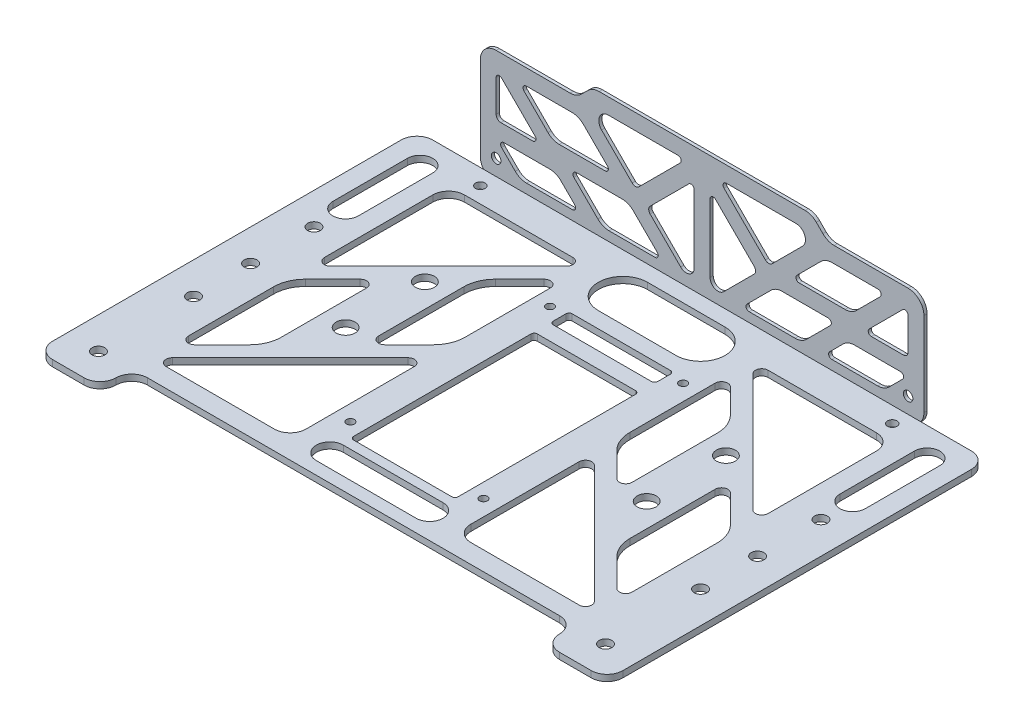
from build123d import *

# Parameters (mm, degrees)
SKETCH_1_R          = 1.25
SKETCH_1_R_2        = 2
SKETCH_1_R_3        = 1.5
SKETCH_1_R_4        = 3
EXTRUDE_1_DEPTH     = 2
SKETCH_3_W          = 33
SKETCH_3_H          = 6
SKETCH_3_H_2        = 58
CUT_EXTRUDE_2_DEPTH = 3
SKETCH_4_R          = 1.5
EXTRUDE_2_DEPTH     = 1
CUT_EXTRUDE_3_DEPTH = 122
CUT_EXTRUDE_4_DEPTH = 3
FILLET_1_R          = 1


with BuildPart() as part:
    # 草图1 → 凸台-拉伸1 (new body)
    with BuildSketch(Plane(origin=(0, 0, 0), x_dir=(1, 0, 0), z_dir=(0, 1, 0))):
        with BuildLine():
            Line((-85, 58.5), (85, 58.5))
            ThreePointArc((85, 58.5), (88.535533906, 57.035533906), (90, 53.5))
            Line((90, 53.5), (90, -56.5))
            ThreePointArc((90, -56.5), (88.535533906, -60.035533906), (85, -61.5))
            Line((85, -61.5), (75, -61.5))
            ThreePointArc((75, -61.5), (71.464466094, -60.035533906), (70, -56.5))
            ThreePointArc((70, -56.5), (68.535533906, -52.964466094), (65, -51.5))
            Line((65, -51.5), (-65, -51.5))
            ThreePointArc((-65, -51.5), (-68.535533906, -52.964466094), (-70, -56.5))
            ThreePointArc((-70, -56.5), (-71.464466094, -60.035533906), (-75, -61.5))
            Line((-75, -61.5), (-85, -61.5))
            ThreePointArc((-85, -61.5), (-88.535533906, -60.035533906), (-90, -56.5))
            Line((-90, -56.5), (-90, 53.5))
            ThreePointArc((-90, 53.5), (-88.535533906, 57.035533906), (-85, 58.5))
        make_face()
        with Locations((-21, 31.5)):
            Circle(SKETCH_1_R, mode=Mode.SUBTRACT)
        with Locations((-21, -31.5)):
            Circle(SKETCH_1_R, mode=Mode.SUBTRACT)
        with Locations((21, -31.5)):
            Circle(SKETCH_1_R, mode=Mode.SUBTRACT)
        with Locations((21, 31.5)):
            Circle(SKETCH_1_R, mode=Mode.SUBTRACT)
        with Locations((-80, -52)):
            Circle(SKETCH_1_R_2, mode=Mode.SUBTRACT)
        with Locations((80, -52)):
            Circle(SKETCH_1_R_2, mode=Mode.SUBTRACT)
        with Locations((-80, 16)):
            Circle(SKETCH_1_R_2, mode=Mode.SUBTRACT)
        with Locations((-80, -4)):
            Circle(SKETCH_1_R_2, mode=Mode.SUBTRACT)
        with Locations((-80, -22)):
            Circle(SKETCH_1_R_2, mode=Mode.SUBTRACT)
        with Locations((80, -22)):
            Circle(SKETCH_1_R_2, mode=Mode.SUBTRACT)
        with Locations((80, -4)):
            Circle(SKETCH_1_R_2, mode=Mode.SUBTRACT)
        with Locations((80, 16)):
            Circle(SKETCH_1_R_2, mode=Mode.SUBTRACT)
        with Locations((-65, 53.5)):
            Circle(SKETCH_1_R_3, mode=Mode.SUBTRACT)
        with Locations((65, 53.5)):
            Circle(SKETCH_1_R_3, mode=Mode.SUBTRACT)
        with Locations((-47.5, -6.5)):
            Circle(SKETCH_1_R_4, mode=Mode.SUBTRACT)
        with Locations((-47.5, 18.5)):
            Circle(SKETCH_1_R_4, mode=Mode.SUBTRACT)
        with Locations((47.5, 18.5)):
            Circle(SKETCH_1_R_4, mode=Mode.SUBTRACT)
        with Locations((47.5, -6.5)):
            Circle(SKETCH_1_R_4, mode=Mode.SUBTRACT)
    extrude(amount=EXTRUDE_1_DEPTH)

    # 草图3 → 切除-拉伸2 (cut, through all)
    with BuildSketch(Plane(origin=(0, 2, 0), x_dir=(1, 0, 0), z_dir=(0, 1, 0))):
        with Locations((0, 30)):
            Rectangle(SKETCH_3_W, SKETCH_3_H)
        with Locations((0, -7)):
            Rectangle(SKETCH_3_W, SKETCH_3_H_2)
    extrude(amount=-CUT_EXTRUDE_2_DEPTH, mode=Mode.SUBTRACT)

    # 草图6 → 切除-拉伸4 (cut, through all)
    with BuildSketch(Plane(origin=(0, 2, 0), x_dir=(1, 0, 0), z_dir=(0, 1, 0))):
        with BuildLine():
            Line((-65, 48.5), (-30.828427125, 48.5))
            ThreePointArc((-30.828427125, 48.5), (-28.98066806, 47.265366865), (-29.414213562, 45.085786438))
            Line((-29.414213562, 45.085786438), (-66.585786438, 7.914213562))
            ThreePointArc((-66.585786438, 7.914213562), (-68.765366865, 7.48066806), (-70, 9.328427125))
            Line((-70, 9.328427125), (-70, 43.5))
            ThreePointArc((-70, 43.5), (-68.535533906, 47.035533906), (-65, 48.5))
        make_face()
        with BuildLine():
            Line((-26, -6.328427125), (-26, -40.5))
            ThreePointArc((-26, -40.5), (-27.464466094, -44.035533906), (-31, -45.5))
            Line((-31, -45.5), (-65.171572875, -45.5))
            ThreePointArc((-65.171572875, -45.5), (-67.01933194, -44.265366865), (-66.585786438, -42.085786438))
            Line((-66.585786438, -42.085786438), (-29.414213562, -4.914213562))
            ThreePointArc((-29.414213562, -4.914213562), (-27.234633135, -4.48066806), (-26, -6.328427125))
        make_face()
        with BuildLine():
            Line((-55, 7.600505063), (-55, -19.286796564))
            ThreePointArc((-55, -19.286796564), (-55.761204675, -23.113630888), (-57.928932188, -26.357864376))
            Line((-57.928932188, -26.357864376), (-66.585786438, -35.014718626))
            ThreePointArc((-66.585786438, -35.014718626), (-68.765366865, -35.448264128), (-70, -33.600505063))
            Line((-70, -33.600505063), (-70, -6.713203436))
            ThreePointArc((-70, -6.713203436), (-69.238795325, -2.886369112), (-67.071067812, 0.357864376))
            Line((-67.071067812, 0.357864376), (-58.414213562, 9.014718626))
            ThreePointArc((-58.414213562, 9.014718626), (-56.234633135, 9.448264128), (-55, 7.600505063))
        make_face()
        with BuildLine():
            Line((-40, 23.286796564), (-40, -3.600505063))
            ThreePointArc((-40, -3.600505063), (-38.765366865, -5.448264128), (-36.585786438, -5.014718626))
            Line((-36.585786438, -5.014718626), (-28.928932188, 2.642135624))
            ThreePointArc((-28.928932188, 2.642135624), (-26.761204675, 5.886369112), (-26, 9.713203436))
            Line((-26, 9.713203436), (-26, 36.600505063))
            ThreePointArc((-26, 36.600505063), (-27.234633135, 38.448264128), (-29.414213562, 38.014718626))
            Line((-29.414213562, 38.014718626), (-37.071067812, 30.357864376))
            ThreePointArc((-37.071067812, 30.357864376), (-39.238795325, 27.113630888), (-40, 23.286796564))
        make_face()
        with BuildLine():
            Line((-12.25, 53.5), (12.25, 53.5))
            ThreePointArc((12.25, 53.5), (20, 45.75), (12.25, 38))
            Line((12.25, 38), (-12.25, 38))
            ThreePointArc((-12.25, 38), (-20, 45.75), (-12.25, 53.5))
        make_face()
        with BuildLine():
            Line((15.75, -47.5), (-15.75, -47.5))
            ThreePointArc((-15.75, -47.5), (-20, -43.25), (-15.75, -39))
            Line((-15.75, -39), (15.75, -39))
            ThreePointArc((15.75, -39), (20, -43.25), (15.75, -47.5))
        make_face()
        with BuildLine():
            Line((29.414213562, 38.014718626), (37.071067812, 30.357864376))
            ThreePointArc((37.071067812, 30.357864376), (39.238795325, 27.113630888), (40, 23.286796564))
            Line((40, 23.286796564), (40, -3.600505063))
            ThreePointArc((40, -3.600505063), (38.765366865, -5.448264128), (36.585786438, -5.014718626))
            Line((36.585786438, -5.014718626), (28.928932188, 2.642135624))
            ThreePointArc((28.928932188, 2.642135624), (26.761204675, 5.886369112), (26, 9.713203436))
            Line((26, 9.713203436), (26, 36.600505063))
            ThreePointArc((26, 36.600505063), (27.234633135, 38.448264128), (29.414213562, 38.014718626))
        make_face()
        with BuildLine():
            Line((67.071067812, 0.357864376), (58.414213562, 9.014718626))
            ThreePointArc((58.414213562, 9.014718626), (56.234633135, 9.448264128), (55, 7.600505063))
            Line((55, 7.600505063), (55, -19.286796564))
            ThreePointArc((55, -19.286796564), (55.761204675, -23.113630888), (57.928932188, -26.357864376))
            Line((57.928932188, -26.357864376), (66.585786438, -35.014718626))
            ThreePointArc((66.585786438, -35.014718626), (68.765366865, -35.448264128), (70, -33.600505063))
            Line((70, -33.600505063), (70, -6.713203436))
            ThreePointArc((70, -6.713203436), (69.238795325, -2.886369112), (67.071067812, 0.357864376))
        make_face()
        with BuildLine():
            Line((66.585786438, -42.085786438), (29.414213562, -4.914213562))
            ThreePointArc((29.414213562, -4.914213562), (27.234633135, -4.48066806), (26, -6.328427125))
            Line((26, -6.328427125), (26, -40.5))
            ThreePointArc((26, -40.5), (27.464466094, -44.035533906), (31, -45.5))
            Line((31, -45.5), (65.171572875, -45.5))
            ThreePointArc((65.171572875, -45.5), (67.01933194, -44.265366865), (66.585786438, -42.085786438))
        make_face()
        with BuildLine():
            Line((70, 9.328427125), (70, 43.5))
            ThreePointArc((70, 43.5), (68.535533906, 47.035533906), (65, 48.5))
            Line((65, 48.5), (30.828427125, 48.5))
            ThreePointArc((30.828427125, 48.5), (28.98066806, 47.265366865), (29.414213562, 45.085786438))
            Line((29.414213562, 45.085786438), (66.585786438, 7.914213562))
            ThreePointArc((66.585786438, 7.914213562), (68.765366865, 7.48066806), (70, 9.328427125))
        make_face()
        with BuildLine():
            Line((-76, 49.5), (-76, 26))
            ThreePointArc((-76, 26), (-80, 22), (-84, 26))
            Line((-84, 26), (-84, 49.5))
            ThreePointArc((-84, 49.5), (-80, 53.5), (-76, 49.5))
        make_face()
        with BuildLine():
            Line((76, 49.5), (76, 26))
            ThreePointArc((76, 26), (80, 22), (84, 26))
            Line((84, 26), (84, 49.5))
            ThreePointArc((84, 49.5), (80, 53.5), (76, 49.5))
        make_face()
    extrude(amount=-CUT_EXTRUDE_4_DEPTH, mode=Mode.SUBTRACT)

    # 圆角1
    fillet_1_edges = [part.edges().sort_by_distance(p)[0] for p in [
        (16.5, 1, -22),
        (16.5, 1, 36),
        (-16.5, 1, 36),
        (-16.5, 1, -22),
        (16.5, 1, -33),
        (16.5, 1, -27),
        (-16.5, 1, -27),
        (-16.5, 1, -33),
    ]]
    fillet(fillet_1_edges, radius=FILLET_1_R)


with BuildPart() as body_2:
    # 草图4 → 凸台-拉伸2 (new body)
    with BuildSketch(Plane(origin=(0, 0, -58.5), x_dir=(-1, 0, 0), z_dir=(0, 0, -1))):
        with BuildLine():
            Line((-70, 31.5), (-70, 5))
            ThreePointArc((-70, 5), (-68.535533906, 1.464466094), (-65, 0))
            Line((-65, 0), (65, 0))
            ThreePointArc((65, 0), (68.535533906, 1.464466094), (70, 5))
            Line((70, 5), (70, 31.5))
            ThreePointArc((70, 31.5), (68.535533906, 35.035533906), (65, 36.5))
            Line((65, 36.5), (41.642135624, 36.5))
            ThreePointArc((41.642135624, 36.5), (39.728718462, 36.880602337), (38.106601718, 37.964466094))
            Line((38.106601718, 37.964466094), (36.035533906, 40.035533906))
            ThreePointArc((36.035533906, 40.035533906), (34.413417162, 41.119397663), (32.5, 41.5))
            Line((32.5, 41.5), (-32.5, 41.5))
            ThreePointArc((-32.5, 41.5), (-34.413417162, 41.119397663), (-36.035533906, 40.035533906))
            Line((-36.035533906, 40.035533906), (-38.106601718, 37.964466094))
            ThreePointArc((-38.106601718, 37.964466094), (-39.728718462, 36.880602337), (-41.642135624, 36.5))
            Line((-41.642135624, 36.5), (-65, 36.5))
            ThreePointArc((-65, 36.5), (-68.535533906, 35.035533906), (-70, 31.5))
        make_face()
        with Locations((-65, 7)):
            Circle(SKETCH_4_R, mode=Mode.SUBTRACT)
        with Locations((65, 7)):
            Circle(SKETCH_4_R, mode=Mode.SUBTRACT)
    extrude(amount=EXTRUDE_2_DEPTH)

    # 草图5 → 切除-拉伸3 (cut, through all)
    with BuildSketch(Plane(origin=(0, 0, -59.5), x_dir=(-1, 0, 0), z_dir=(0, 0, -1))):
        with BuildLine():
            Line((-29.615223689, 36.5), (-7.596194078, 36.5))
            ThreePointArc((-7.596194078, 36.5), (-6.672314545, 35.882683432), (-6.889087297, 34.792893219))
            Line((-6.889087297, 34.792893219), (-19.959262274, 21.722718241))
            ThreePointArc((-19.959262274, 21.722718241), (-21.019922446, 21.283378413), (-22.080582618, 21.722718241))
            Line((-22.080582618, 21.722718241), (-31.736544033, 31.378679656))
            ThreePointArc((-31.736544033, 31.378679656), (-32.386862287, 34.648050297), (-29.615223689, 36.5))
        make_face()
        with BuildLine():
            Line((-2.5, 29.696699141), (-2.5, 8.17766953))
            ThreePointArc((-2.5, 8.17766953), (-4.043291419, 5.867970698), (-6.767766953, 6.409902577))
            Line((-6.767766953, 6.409902577), (-16.423728368, 16.065863992))
            ThreePointArc((-16.423728368, 16.065863992), (-16.863068196, 17.126524164), (-16.423728368, 18.187184335))
            Line((-16.423728368, 18.187184335), (-4.207106781, 30.403805922))
            ThreePointArc((-4.207106781, 30.403805922), (-3.117316568, 30.620578674), (-2.5, 29.696699141))
        make_face()
        with BuildLine():
            Line((52.707106781, 19.207106781), (63.292893219, 29.792893219))
            ThreePointArc((63.292893219, 29.792893219), (64.382683432, 30.00966597), (65, 29.085786438))
            Line((65, 29.085786438), (65, 19))
            ThreePointArc((65, 19), (64.560660172, 17.939339828), (63.5, 17.5))
            Line((63.5, 17.5), (53.414213562, 17.5))
            ThreePointArc((53.414213562, 17.5), (52.49033403, 18.117316568), (52.707106781, 19.207106781))
        make_face()
        with BuildLine():
            Line((45.107864376, 20.75), (30.593145751, 20.75))
            ThreePointArc((30.593145751, 20.75), (29.669266218, 21.367316568), (29.886038969, 22.457106781))
            Line((29.886038969, 22.457106781), (37.464466094, 30.035533906))
            ThreePointArc((37.464466094, 30.035533906), (39.086582838, 31.119397663), (41, 31.5))
            Line((41, 31.5), (55.514718626, 31.5))
            ThreePointArc((55.514718626, 31.5), (56.438598158, 30.882683432), (56.221825407, 29.792893219))
            Line((56.221825407, 29.792893219), (48.643398282, 22.214466094))
            ThreePointArc((48.643398282, 22.214466094), (47.021281538, 21.130602337), (45.107864376, 20.75))
        make_face()
        with BuildLine():
            Line((-62.585786438, 12.5), (-48.071067812, 12.5))
            ThreePointArc((-48.071067812, 12.5), (-46.15765065, 12.119397663), (-44.535533906, 11.035533906))
            Line((-44.535533906, 11.035533906), (-40.207106781, 6.707106781))
            ThreePointArc((-40.207106781, 6.707106781), (-39.99033403, 5.617316568), (-40.914213562, 5))
            Line((-40.914213562, 5), (-55.428932188, 5))
            ThreePointArc((-55.428932188, 5), (-57.34234935, 5.380602337), (-58.964466094, 6.464466094))
            Line((-58.964466094, 6.464466094), (-63.292893219, 10.792893219))
            ThreePointArc((-63.292893219, 10.792893219), (-63.50966597, 11.882683432), (-62.585786438, 12.5))
        make_face()
        with BuildLine():
            Line((-55.514718626, 31.5), (-41, 31.5))
            ThreePointArc((-41, 31.5), (-39.086582838, 31.119397663), (-37.464466094, 30.035533906))
            Line((-37.464466094, 30.035533906), (-29.886038969, 22.457106781))
            ThreePointArc((-29.886038969, 22.457106781), (-29.669266218, 21.367316568), (-30.593145751, 20.75))
            Line((-30.593145751, 20.75), (-45.107864376, 20.75))
            ThreePointArc((-45.107864376, 20.75), (-47.021281538, 21.130602337), (-48.643398282, 22.214466094))
            Line((-48.643398282, 22.214466094), (-56.221825407, 29.792893219))
            ThreePointArc((-56.221825407, 29.792893219), (-56.438598158, 30.882683432), (-55.514718626, 31.5))
        make_face()
        with BuildLine():
            Line((-65, 29.085786438), (-65, 19))
            ThreePointArc((-65, 19), (-64.560660172, 17.939339828), (-63.5, 17.5))
            Line((-63.5, 17.5), (-53.414213562, 17.5))
            ThreePointArc((-53.414213562, 17.5), (-52.49033403, 18.117316568), (-52.707106781, 19.207106781))
            Line((-52.707106781, 19.207106781), (-63.292893219, 29.792893219))
            ThreePointArc((-63.292893219, 29.792893219), (-64.382683432, 30.00966597), (-65, 29.085786438))
        make_face()
        with BuildLine():
            Line((55.428932188, 5), (40.914213562, 5))
            ThreePointArc((40.914213562, 5), (39.99033403, 5.617316568), (40.207106781, 6.707106781))
            Line((40.207106781, 6.707106781), (44.535533906, 11.035533906))
            ThreePointArc((44.535533906, 11.035533906), (46.15765065, 12.119397663), (48.071067812, 12.5))
            Line((48.071067812, 12.5), (62.585786438, 12.5))
            ThreePointArc((62.585786438, 12.5), (63.50966597, 11.882683432), (63.292893219, 10.792893219))
            Line((63.292893219, 10.792893219), (58.964466094, 6.464466094))
            ThreePointArc((58.964466094, 6.464466094), (57.34234935, 5.380602337), (55.428932188, 5))
        make_face()
        with BuildLine():
            Line((6.767766953, 6.409902577), (16.423728368, 16.065863992))
            ThreePointArc((16.423728368, 16.065863992), (16.863068196, 17.126524164), (16.423728368, 18.187184335))
            Line((16.423728368, 18.187184335), (4.207106781, 30.403805922))
            ThreePointArc((4.207106781, 30.403805922), (3.117316568, 30.620578674), (2.5, 29.696699141))
            Line((2.5, 29.696699141), (2.5, 8.17766953))
            ThreePointArc((2.5, 8.17766953), (4.043291419, 5.867970698), (6.767766953, 6.409902577))
        make_face()
        with BuildLine():
            Line((29.615223689, 36.5), (7.596194078, 36.5))
            ThreePointArc((7.596194078, 36.5), (6.672314545, 35.882683432), (6.889087297, 34.792893219))
            Line((6.889087297, 34.792893219), (19.959262274, 21.722718241))
            ThreePointArc((19.959262274, 21.722718241), (21.019922446, 21.283378413), (22.080582618, 21.722718241))
            Line((22.080582618, 21.722718241), (31.736544033, 31.378679656))
            ThreePointArc((31.736544033, 31.378679656), (32.386862287, 34.648050297), (29.615223689, 36.5))
        make_face()
        with BuildLine():
            Line((-29.357864376, 5), (-14.843145751, 5))
            ThreePointArc((-14.843145751, 5), (-13.919266218, 5.617316568), (-14.136038969, 6.707106781))
            Line((-14.136038969, 6.707106781), (-21.714466094, 14.285533906))
            ThreePointArc((-21.714466094, 14.285533906), (-23.336582838, 15.369397663), (-25.25, 15.75))
            Line((-25.25, 15.75), (-39.764718626, 15.75))
            ThreePointArc((-39.764718626, 15.75), (-40.688598158, 15.132683432), (-40.471825407, 14.042893219))
            Line((-40.471825407, 14.042893219), (-32.893398282, 6.464466094))
            ThreePointArc((-32.893398282, 6.464466094), (-31.271281538, 5.380602337), (-29.357864376, 5))
        make_face()
        with BuildLine():
            Line((21.714466094, 14.285533906), (14.136038969, 6.707106781))
            ThreePointArc((14.136038969, 6.707106781), (13.919266218, 5.617316568), (14.843145751, 5))
            Line((14.843145751, 5), (29.357864376, 5))
            ThreePointArc((29.357864376, 5), (31.271281538, 5.380602337), (32.893398282, 6.464466094))
            Line((32.893398282, 6.464466094), (40.471825407, 14.042893219))
            ThreePointArc((40.471825407, 14.042893219), (40.688598158, 15.132683432), (39.764718626, 15.75))
            Line((39.764718626, 15.75), (25.25, 15.75))
            ThreePointArc((25.25, 15.75), (23.336582838, 15.369397663), (21.714466094, 14.285533906))
        make_face()
    extrude(amount=-CUT_EXTRUDE_3_DEPTH, mode=Mode.SUBTRACT)


solid = Compound([part.part, body_2.part])
